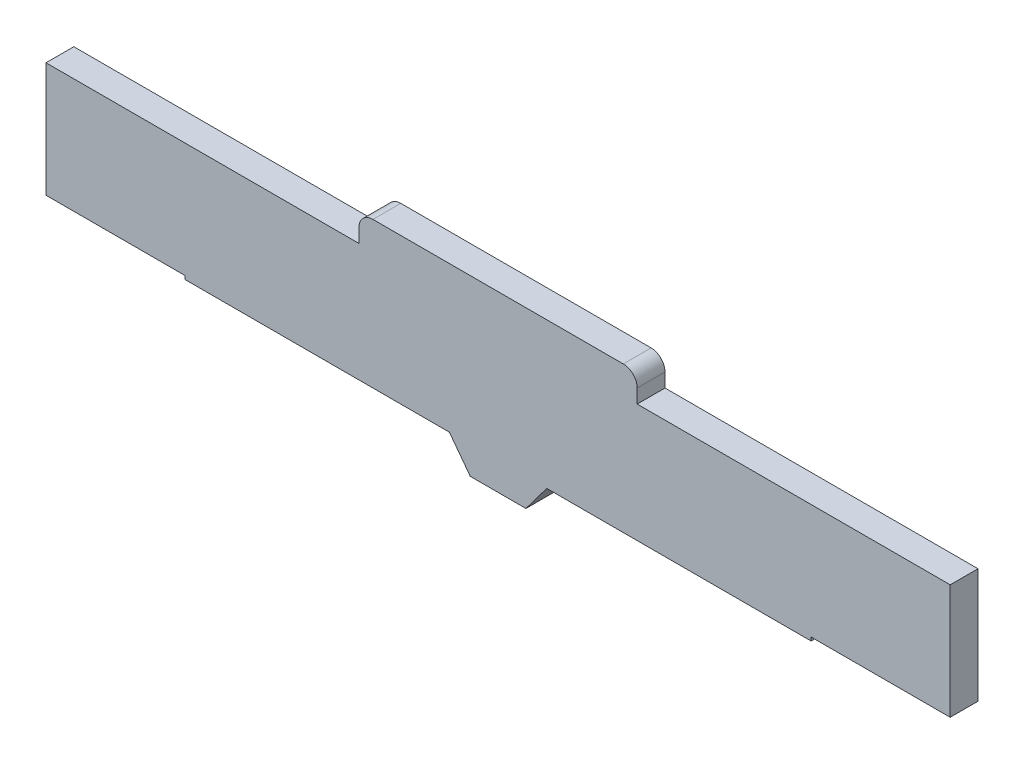
from build123d import *

# Parameters (mm, degrees)
BOSS_EXTRUDE1_DEPTH = 2


with BuildPart() as part:
    # Sketch1 → Boss-Extrude1 (new body)
    with BuildSketch(Plane.XY):
        with BuildLine():
            Line((-26.329238207, -11.829238207), (-26.329238207, -10.829238207))
            ThreePointArc((-26.329238207, -10.829238207), (-26.036344989, -10.122131426), (-25.329238207, -9.829238207))
            Line((-25.329238207, -9.829238207), (-7.329238207, -9.829238207))
            ThreePointArc((-7.329238207, -9.829238207), (-6.622131426, -10.122131426), (-6.329238207, -10.829238207))
            Line((-6.329238207, -10.829238207), (-6.329238207, -11.829238207))
            Line((-6.329238207, -11.829238207), (16.170761793, -11.829238207))
            Line((16.170761793, -11.829238207), (16.170761793, -20.079238207))
            Line((16.170761793, -20.079238207), (6.170761793, -20.079238207))
            Line((6.170761793, -20.079238207), (6.170761793, -20.329238207))
            Line((6.170761793, -20.329238207), (-12.829238207, -20.329238207))
            Line((-12.829238207, -20.329238207), (-14.329238207, -22.329238207))
            Line((-14.329238207, -22.329238207), (-16.329238207, -22.329238207))
            Line((-16.329238207, -22.329238207), (-18.329238207, -22.329238207))
            Line((-18.329238207, -22.329238207), (-19.829238207, -20.329238207))
            Line((-19.829238207, -20.329238207), (-38.829238207, -20.329238207))
            Line((-38.829238207, -20.329238207), (-38.829238207, -20.079238207))
            Line((-38.829238207, -20.079238207), (-48.829238207, -20.079238207))
            Line((-48.829238207, -20.079238207), (-48.829238207, -11.829238207))
            Line((-48.829238207, -11.829238207), (-26.329238207, -11.829238207))
        make_face()
    extrude(amount=BOSS_EXTRUDE1_DEPTH)


solid = part.part
